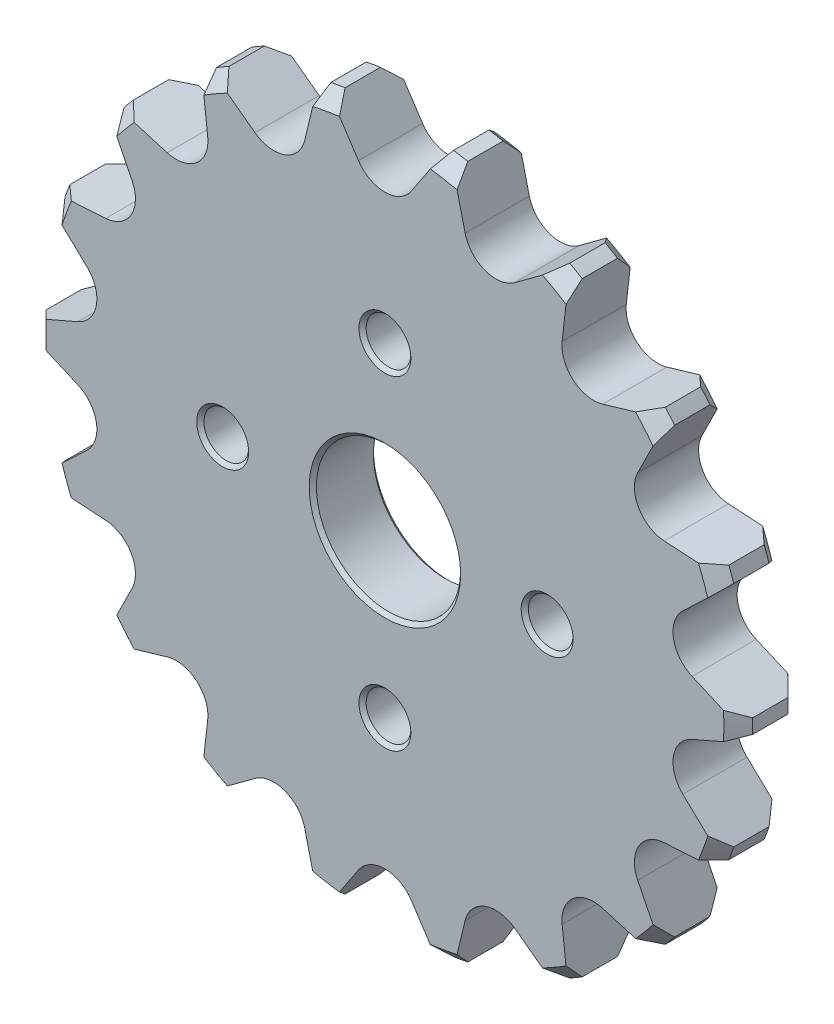
from build123d import *

# Parameters (mm, degrees)
SZKIC1_R                    = 49
DODANIE_WYCI_GNI_CIE1_DEPTH = 8.9
SFAZOWANIE1_SIZE            = 2
WYTNIJ_WYCI_GNI_CIE1_DEPTH  = 8.9
SZYK_KO_OWY1_COUNT          = 18
WYTNIJ_WYCI_GNI_CIE2_REACH  = 10.9
SZKIC3_R                    = 10
WYTNIJ_WYCI_GNI_CIE3_REACH  = 10.9
SZKIC4_R                    = 3.1
SFAZOWANIE2_SIZE            = 0.5


with BuildPart() as part:
    # Szkic1 → Dodanie-wyciągnięcie1 (new body)
    with BuildSketch(Plane.XY):
        Circle(SZKIC1_R)
    extrude(amount=DODANIE_WYCI_GNI_CIE1_DEPTH)

    # Sfazowanie1
    sfazowanie1_edges = [part.edges().sort_by_distance(p)[0] for p in [
        (-49, 0, 0),
        (-49, 0, 8.9),
    ]]
    chamfer(sfazowanie1_edges, length=SFAZOWANIE1_SIZE)

    # Szkic2 → Wytnij-wyciągnięcie1 (cut)
    with BuildSketch(Plane(origin=(0, 0, 0), x_dir=(-1, 0, 0), z_dir=(0, 0, 1))):
        with BuildLine():
            Line((7.522232305, 48.419169976), (5.333261975, 45.114131731))
            Line((5.333261975, 45.114131731), (3.668375503, 42.600386622))
            ThreePointArc((3.668375503, 42.600386622), (0, 40.63), (-3.668375503, 42.600386622))
            Line((-3.668375503, 42.600386622), (-5.333261975, 45.114131731))
            Line((-5.333261975, 45.114131731), (-7.522232305, 48.419169976))
            ThreePointArc((-7.522232305, 48.419169976), (0, 49), (7.522232305, 48.419169976))
        make_face()
    wytnij_wyci_gni_cie1 = extrude(amount=WYTNIJ_WYCI_GNI_CIE1_DEPTH, mode=Mode.SUBTRACT)

    # Szyk kołowy1: Wytnij-wyciągnięcie1 ×18 about axis
    szyk_ko_owy1_axis = Axis((0, 0, 0), (0, 0, 1))
    for i in range(1, SZYK_KO_OWY1_COUNT):
        add(wytnij_wyci_gni_cie1.rotate(szyk_ko_owy1_axis, i * 360 / SZYK_KO_OWY1_COUNT), mode=Mode.SUBTRACT)

    # Szkic3 → Wytnij-wyciągnięcie2 (cut, up to next)
    with BuildSketch(Plane.XY.offset(8.9), mode=Mode.PRIVATE) as wytnij_wyci_gni_cie2_sk1:
        Circle(SZKIC3_R)
    wytnij_wyci_gni_cie2_tool1 = extrude(wytnij_wyci_gni_cie2_sk1.sketch, amount=-WYTNIJ_WYCI_GNI_CIE2_REACH, mode=Mode.PRIVATE) & part.part
    add(wytnij_wyci_gni_cie2_tool1.solids().sort_by_distance((0, 0, 8.9))[0], mode=Mode.SUBTRACT)

    # Szkic4 → Wytnij-wyciągnięcie3 (cut, up to next)
    with BuildSketch(Plane.XY.offset(8.9), mode=Mode.PRIVATE) as wytnij_wyci_gni_cie3_sk1:
        with Locations((0, 22.5)):
            Circle(SZKIC4_R)
    wytnij_wyci_gni_cie3_tool1 = extrude(wytnij_wyci_gni_cie3_sk1.sketch, amount=-WYTNIJ_WYCI_GNI_CIE3_REACH, mode=Mode.PRIVATE) & part.part
    add(wytnij_wyci_gni_cie3_tool1.solids().sort_by_distance((0, 22.5, 8.9))[0], mode=Mode.SUBTRACT)
    # Szkic4 → Wytnij-wyciągnięcie3 (cut, up to next)
    with BuildSketch(Plane.XY.offset(8.9), mode=Mode.PRIVATE) as wytnij_wyci_gni_cie3_sk2:
        with Locations((22.5, 0)):
            Circle(SZKIC4_R)
    wytnij_wyci_gni_cie3_tool2 = extrude(wytnij_wyci_gni_cie3_sk2.sketch, amount=-WYTNIJ_WYCI_GNI_CIE3_REACH, mode=Mode.PRIVATE) & part.part
    add(wytnij_wyci_gni_cie3_tool2.solids().sort_by_distance((22.5, 0, 8.9))[0], mode=Mode.SUBTRACT)
    # Szkic4 → Wytnij-wyciągnięcie3 (cut, up to next)
    with BuildSketch(Plane.XY.offset(8.9), mode=Mode.PRIVATE) as wytnij_wyci_gni_cie3_sk3:
        with Locations((0, -22.5)):
            Circle(SZKIC4_R)
    wytnij_wyci_gni_cie3_tool3 = extrude(wytnij_wyci_gni_cie3_sk3.sketch, amount=-WYTNIJ_WYCI_GNI_CIE3_REACH, mode=Mode.PRIVATE) & part.part
    add(wytnij_wyci_gni_cie3_tool3.solids().sort_by_distance((0, -22.5, 8.9))[0], mode=Mode.SUBTRACT)
    # Szkic4 → Wytnij-wyciągnięcie3 (cut, up to next)
    with BuildSketch(Plane.XY.offset(8.9), mode=Mode.PRIVATE) as wytnij_wyci_gni_cie3_sk4:
        with Locations((-22.5, 0)):
            Circle(SZKIC4_R)
    wytnij_wyci_gni_cie3_tool4 = extrude(wytnij_wyci_gni_cie3_sk4.sketch, amount=-WYTNIJ_WYCI_GNI_CIE3_REACH, mode=Mode.PRIVATE) & part.part
    add(wytnij_wyci_gni_cie3_tool4.solids().sort_by_distance((-22.5, 0, 8.9))[0], mode=Mode.SUBTRACT)

    # Sfazowanie2
    sfazowanie2_edges = [part.edges().sort_by_distance(p)[0] for p in [
        (-10, 0, 8.9),
        (-10, 0, 0),
        (-3.1, 22.5, 8.9),
        (-3.1, 22.5, 0),
        (19.4, 0, 8.9),
        (19.4, 0, 0),
        (-3.1, -22.5, 8.9),
        (-3.1, -22.5, 0),
        (-25.6, 0, 8.9),
        (-25.6, 0, 0),
    ]]
    chamfer(sfazowanie2_edges, length=SFAZOWANIE2_SIZE)


solid = part.part
